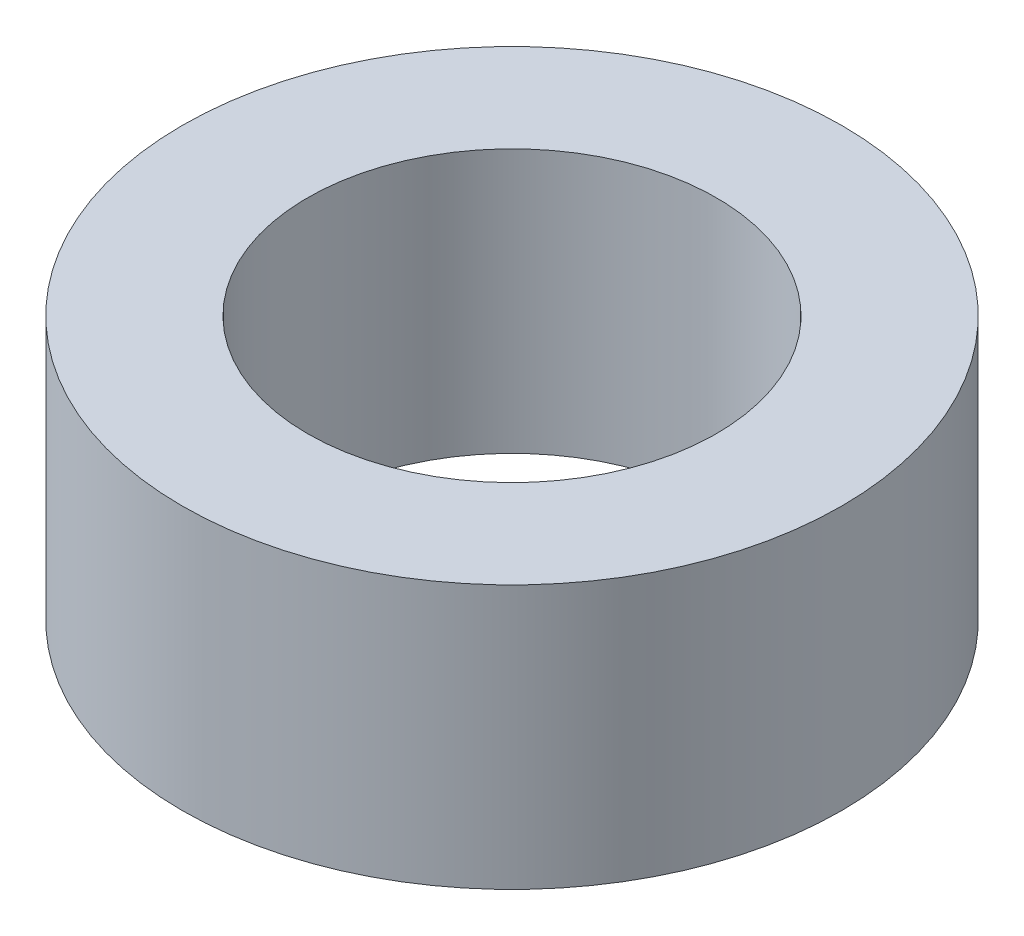
from build123d import *

# Parameters (mm, degrees)
SKETCH_1_R      = 2.5
SKETCH_1_R_2    = 1.55
EXTRUDE_1_DEPTH = 2


with BuildPart() as part:
    # 草图1 → 凸台-拉伸1 (new body)
    with BuildSketch(Plane(origin=(0, 0, 0), x_dir=(1, 0, 0), z_dir=(0, 1, 0))):
        Circle(SKETCH_1_R)
        Circle(SKETCH_1_R_2, mode=Mode.SUBTRACT)
    extrude(amount=EXTRUDE_1_DEPTH)


solid = part.part
